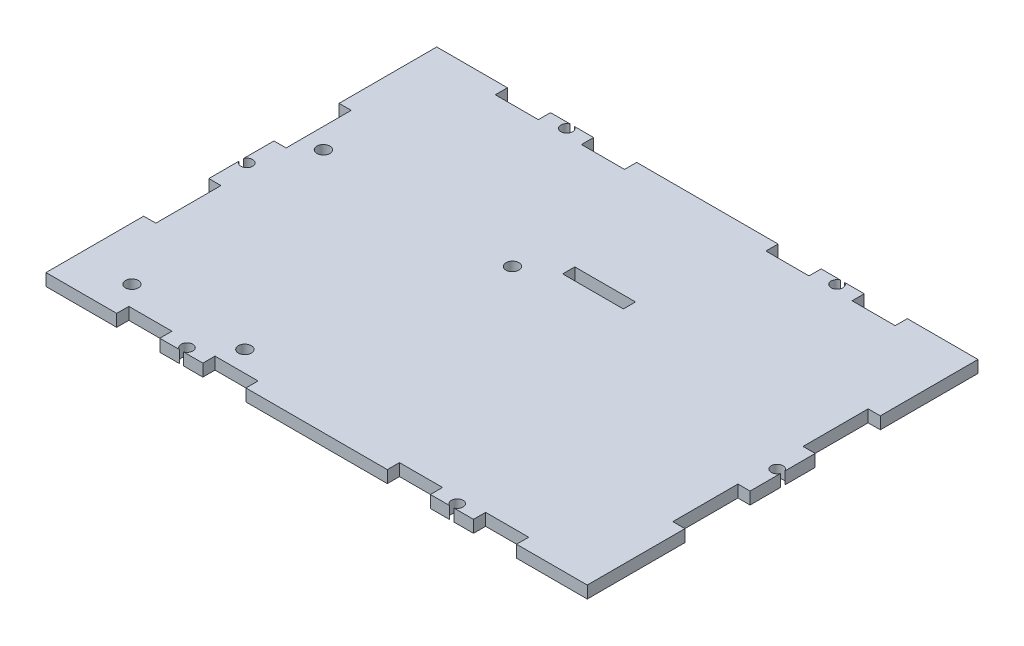
from build123d import *

# Parameters (mm, degrees)
SKETCH1_W                = 133.7
SKETCH1_H                = 96.52
BOSS_EXTRUDE2_DEPTH      = 3
SKETCH6_W                = 48.26
SKETCH6_H                = 3
CUT_EXTRUDE2_DEPTH       = 3
SKETCH9_W                = 16.086666666
SKETCH9_H                = 3
BOSS_EXTRUDE4_DEPTH      = 3
SKETCH11_W               = 31.925
SKETCH11_H               = 3
CUT_EXTRUDE8_DEPTH       = 3
SKETCH15_W               = 10.641666666
SKETCH15_H               = 3
BOSS_EXTRUDE7_DEPTH      = 3
SKETCH18_W               = 31.925
SKETCH18_H               = 3
CUT_EXTRUDE10_DEPTH      = 3
SKETCH19_W               = 10.64166667
SKETCH19_H               = 3
BOSS_EXTRUDE8_DEPTH      = 3
SKETCH21_R               = 1.45
CUT_EXTRUDE11_DEPTH      = 3
MIRROR16_COPY_1_SKETCH_R = 1.45
MIRROR16_COPY_1_DEPTH    = 3
SKETCH22_R               = 1.45
CUT_EXTRUDE19_DEPTH      = 3
SKETCH24_R               = 1.6
CUT_EXTRUDE20_DEPTH      = 3
SKETCH25_W               = 15
SKETCH25_H               = 3
CUT_EXTRUDE21_DEPTH      = 3


with BuildPart() as part:
    # Sketch1 → Boss-Extrude2 (new body)
    with BuildSketch(Plane(origin=(0, 0, 0), x_dir=(1, 0, 0), z_dir=(0, 1, 0))):
        Rectangle(SKETCH1_W, SKETCH1_H)
    extrude(amount=BOSS_EXTRUDE2_DEPTH)

    # Sketch6 → Cut-Extrude2 (cut)
    with BuildSketch(Plane.ZY.offset(66.85)):
        with Locations((0, 1.5)):
            Rectangle(SKETCH6_W, SKETCH6_H)
    cut_extrude2 = extrude(amount=-CUT_EXTRUDE2_DEPTH, mode=Mode.SUBTRACT)

    # Mirror3: Cut-Extrude2 across plane
    add(cut_extrude2.mirror(Plane(origin=(0, 0, 0), x_dir=(0, 0, 1), z_dir=(1, 0, 0))), mode=Mode.SUBTRACT)

    # Sketch9 → Boss-Extrude4 (add)
    with BuildSketch(Plane(origin=(63.85, 0, 0), x_dir=(0, 0, -1), z_dir=(1, 0, 0))):
        with Locations((0, 1.5)):
            Rectangle(SKETCH9_W, SKETCH9_H)
    boss_extrude4 = extrude(amount=BOSS_EXTRUDE4_DEPTH)

    # Mirror5: Boss-Extrude4 across plane
    add(boss_extrude4.mirror(Plane(origin=(0, 0, 0), x_dir=(0, 0, 1), z_dir=(1, 0, 0))))

    # Sketch11 → Cut-Extrude8 (cut)
    with BuildSketch(Plane.XY.offset(48.26)):
        with Locations((-33.425, 1.5)):
            Rectangle(SKETCH11_W, SKETCH11_H)
    cut_extrude8 = extrude(amount=-CUT_EXTRUDE8_DEPTH, mode=Mode.SUBTRACT)

    # Sketch15 → Boss-Extrude7 (add)
    with BuildSketch(Plane.XY.offset(45.26)):
        with Locations((-33.425, 1.5)):
            Rectangle(SKETCH15_W, SKETCH15_H)
    boss_extrude7 = extrude(amount=BOSS_EXTRUDE7_DEPTH)

    # Mirror11: Cut-Extrude8 across plane
    add(cut_extrude8.mirror(Plane.XY), mode=Mode.SUBTRACT)

    # Mirror12: Boss-Extrude7 across plane
    add(boss_extrude7.mirror(Plane.XY))

    # Sketch18 → Cut-Extrude10 (cut)
    with BuildSketch(Plane.XY.offset(48.26)):
        with Locations((33.425, 1.5)):
            Rectangle(SKETCH18_W, SKETCH18_H)
    cut_extrude10 = extrude(amount=-CUT_EXTRUDE10_DEPTH, mode=Mode.SUBTRACT)

    # Sketch19 → Boss-Extrude8 (add)
    with BuildSketch(Plane.XY.offset(45.26)):
        with Locations((33.425, 1.5)):
            Rectangle(SKETCH19_W, SKETCH19_H)
    boss_extrude8 = extrude(amount=BOSS_EXTRUDE8_DEPTH)

    # Mirror13: Cut-Extrude10 across plane
    add(cut_extrude10.mirror(Plane.XY), mode=Mode.SUBTRACT)

    # Mirror14: Boss-Extrude8 across plane
    add(boss_extrude8.mirror(Plane.XY))

    # Sketch21 → Cut-Extrude11 (cut)
    with BuildSketch(Plane(origin=(0, 3, 0), x_dir=(1, 0, 0), z_dir=(0, 1, 0))):
        with Locations((33.375833335, -46.91)):
            Circle(SKETCH21_R)
    cut_extrude11 = extrude(amount=-CUT_EXTRUDE11_DEPTH, mode=Mode.SUBTRACT)

    # Mirror15: Cut-Extrude11 across plane
    add(cut_extrude11.mirror(Plane.XY), mode=Mode.SUBTRACT)

    # Mirror16: Cut-Extrude11 across plane
    add(cut_extrude11.mirror(Plane(origin=(0, 0, 0), x_dir=(0, 0, 1), z_dir=(1, 0, 0))), mode=Mode.SUBTRACT)

    # Mirror16 copy 1 sketch → Mirror16 copy 1 (cut)
    with BuildSketch(Plane(origin=(0, 3, 0), x_dir=(-1, 0, 0), z_dir=(0, 1, 0))):
        with Locations((33.375833335, -46.91)):
            Circle(MIRROR16_COPY_1_SKETCH_R)
    extrude(amount=-MIRROR16_COPY_1_DEPTH, mode=Mode.SUBTRACT)

    # Sketch22 → Cut-Extrude19 (cut)
    with BuildSketch(Plane(origin=(0, 3, 0), x_dir=(1, 0, 0), z_dir=(0, 1, 0))):
        with Locations((65.5, 0)):
            Circle(SKETCH22_R)
    cut_extrude19 = extrude(amount=-CUT_EXTRUDE19_DEPTH, mode=Mode.SUBTRACT)

    # Mirror17: Cut-Extrude19 across plane
    add(cut_extrude19.mirror(Plane(origin=(0, 0, 0), x_dir=(0, 0, 1), z_dir=(1, 0, 0))), mode=Mode.SUBTRACT)

    # Sketch24 → Cut-Extrude20 (cut)
    with BuildSketch(Plane(origin=(0, 3, 0), x_dir=(1, 0, 0), z_dir=(0, 1, 0))):
        with Locations((-53.75, -40.14)):
            Circle(SKETCH24_R)
        with Locations((-25.85, -40.14)):
            Circle(SKETCH24_R)
        with Locations((-10.55, 10.66)):
            Circle(SKETCH24_R)
        with Locations((-58.85, 12.26)):
            Circle(SKETCH24_R)
    extrude(amount=-CUT_EXTRUDE20_DEPTH, mode=Mode.SUBTRACT)

    # Sketch25 → Cut-Extrude21 (cut)
    with BuildSketch(Plane(origin=(0, 3, 0), x_dir=(1, 0, 0), z_dir=(0, 1, 0))):
        with Locations((4.75, 16.76)):
            Rectangle(SKETCH25_W, SKETCH25_H)
    extrude(amount=-CUT_EXTRUDE21_DEPTH, mode=Mode.SUBTRACT)


solid = part.part
